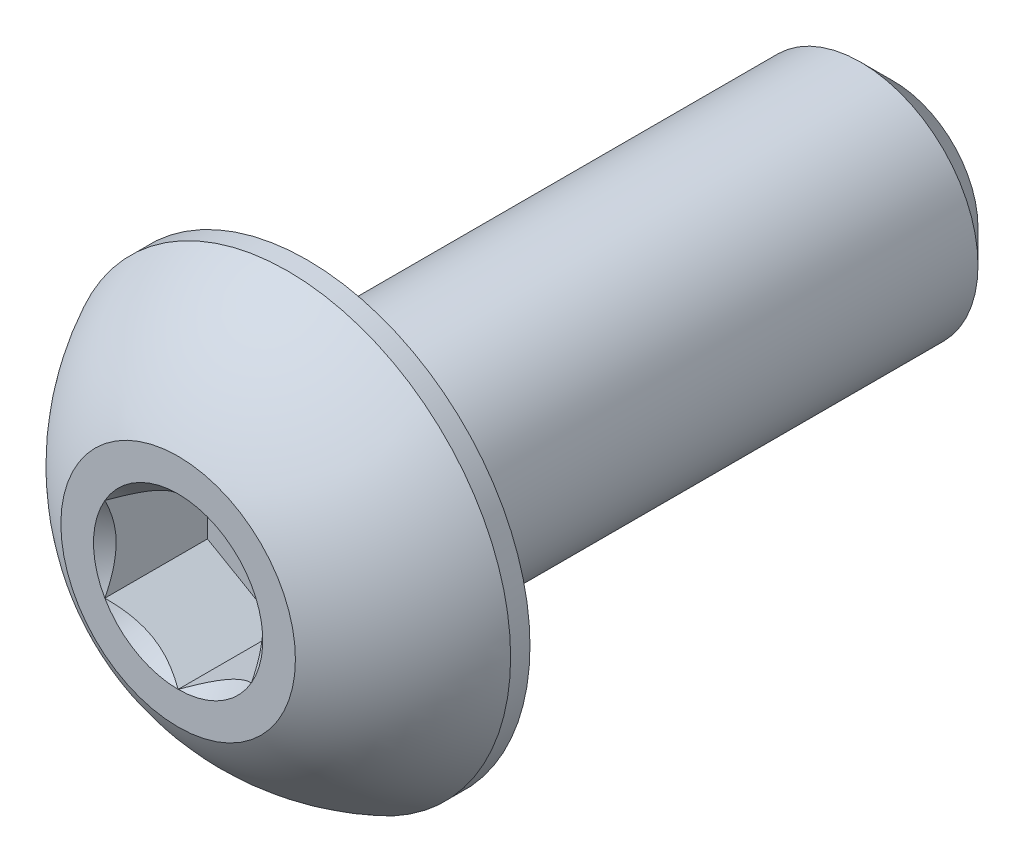
from build123d import *

# Parameters (mm, degrees)
CUT_EXTRUDE1_DEPTH = 1.75


with BuildPart() as part:
    # Sketch2 → Revolve1 (revolve)
    with BuildSketch(Plane(origin=(0, 0, 0), x_dir=(0, 0, -1), z_dir=(1, 0, 0)), mode=Mode.PRIVATE) as revolve1_sk:
        with BuildLine():
            Line((-6.1, 0), (6.1, 0))
            Line((6.1, 0), (6.1, 1.44))
            Line((6.1, 1.44), (5.54, 2))
            Line((5.54, 2), (-3.9, 2))
            Line((-3.9, 2), (-3.9, 3.8))
            Line((-3.9, 3.8), (-4.23, 3.8))
            ThreePointArc((-4.23, 3.8), (-5.306499853, 3.047002626), (-6.1, 2))
            Line((-6.1, 2), (-6.1, 0))
        make_face()
    revolve(revolve1_sk.sketch.rotate(Axis((0, 0, 6.1), (0, 0, -1)), 90), axis=Axis((0, 0, 6.1), (0, 0, -1)))

    # Sketch3 → Cut-Extrude1 (cut)
    with BuildSketch(Plane.XY.offset(6.1)):
        Polygon((0, 1.443375673), (-1.25, 0.721687836), (-1.25, -0.721687836), (0, -1.443375673), (1.25, -0.721687836), (1.25, 0.721687836), align=None)
    extrude(amount=-CUT_EXTRUDE1_DEPTH, mode=Mode.SUBTRACT)

    # Cut-Extrude2 cone 1 section (through the dimple's axis) → Cut-Extrude2 (revolve, cut)
    with BuildSketch(Plane(origin=(0, 0, 6.1), x_dir=(0, -1, 0), z_dir=(1, 0, 0))):
        Polygon((0, 0), (1.443375673, 0), (0, 1.443375673), align=None)
    revolve(axis=Axis((0, 0, 6.1), (0, 0, -1)), mode=Mode.SUBTRACT)


solid = part.part
